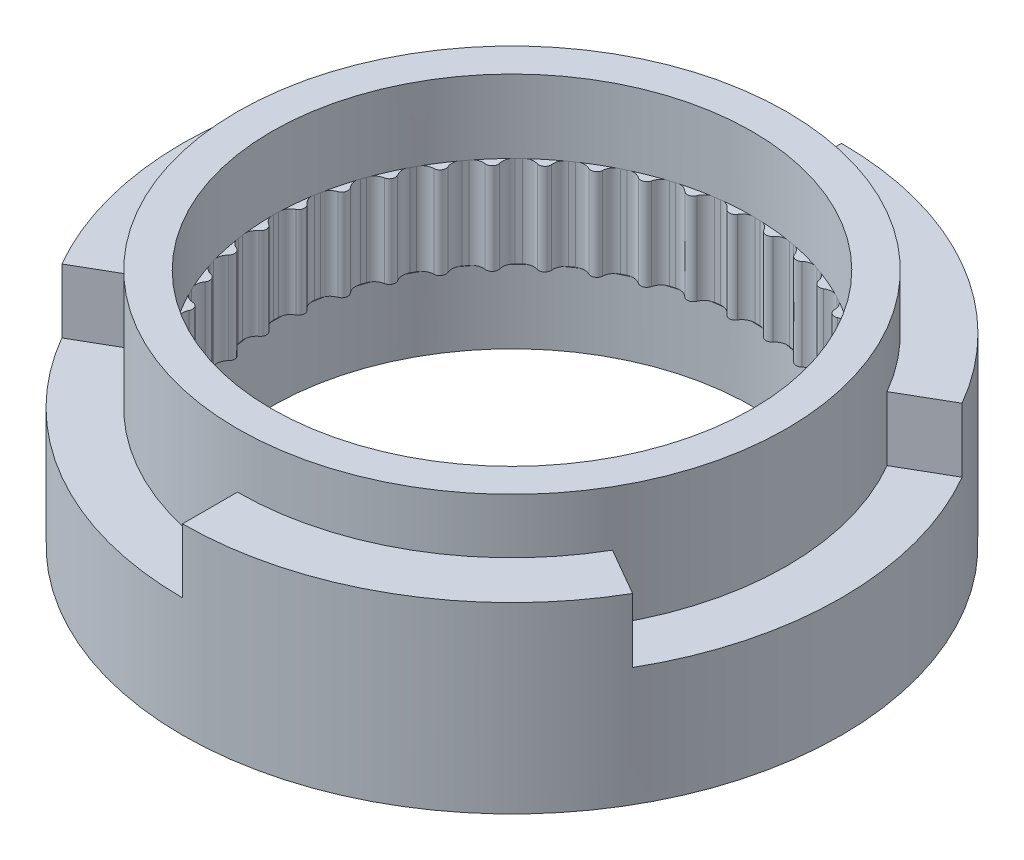
from build123d import *

# Parameters (mm, degrees)
SKETCH1_R                = 30
BOSS_EXTRUDE1_DEPTH      = 5
BOSS_EXTRUDE1_DEPTH_BACK = 5
SKETCH3_R                = 30
SKETCH3_R_2              = 26.25
BOSS_EXTRUDE2_DEPTH      = 8
SKETCH4_R                = 36
SKETCH4_R_2              = 30
BOSS_EXTRUDE3_DEPTH      = 13
BOSS_EXTRUDE4_DEPTH      = 7


with BuildPart() as part:
    # Sketch1 → Boss-Extrude1 (new, two sides)
    with BuildSketch(Plane(origin=(0, 0, 0), x_dir=(0.9998001362045251, 0, 0.01999218961027602), z_dir=(0, 1, 0))) as boss_extrude1_sk:
        with Locations(Location((0, 0, 0), (0, 0, 181.145544407))):
            Circle(SKETCH1_R)
        with BuildLine():
            ThreePointArc((-25.509521388, -2.579136659), (-25.936481137, -3.146205235), (-26.019455243, -3.851170975))
            ThreePointArc((-26.019455243, -3.851170975), (-25.978262474, -4.119884448), (-25.934294667, -4.388157829))
            ThreePointArc((-25.934294667, -4.388157829), (-25.634532236, -5.041831047), (-25.047634104, -5.457399062))
            ThreePointArc((-25.047634104, -5.457399062), (-24.629999462, -5.929109709), (-24.791990986, -6.537951539))
            ThreePointArc((-24.791990986, -6.537951539), (-25.124985082, -7.16482978), (-25.096656701, -7.874096231))
            ThreePointArc((-25.096656701, -7.874096231), (-25.013935035, -8.133057427), (-24.928541342, -8.391149836))
            ThreePointArc((-24.928541342, -8.391149836), (-24.530212463, -8.989882077), (-23.885530861, -9.308522665))
            ThreePointArc((-23.885530861, -9.308522665), (-23.399246192, -9.709093319), (-23.463999485, -10.335780353))
            ThreePointArc((-23.463999485, -10.335780353), (-23.694828509, -11.007032436), (-23.55589518, -11.703135106))
            ThreePointArc((-23.55589518, -11.703135106), (-23.433681498, -11.945967539), (-23.308964596, -12.187523887))
            ThreePointArc((-23.308964596, -12.187523887), (-22.821877448, -12.716572375), (-22.135286577, -12.930439547))
            ThreePointArc((-22.135286577, -12.930439547), (-21.592325823, -13.250006829), (-21.558246445, -13.879107953))
            ThreePointArc((-21.558246445, -13.879107953), (-21.68122662, -14.578205424), (-21.435109342, -15.244003953))
            ThreePointArc((-21.435109342, -15.244003953), (-21.276412952, -15.464728285), (-21.115443783, -15.683800651))
            ThreePointArc((-21.115443783, -15.683800651), (-20.55159207, -16.130138457), (-19.839998074, -16.233966094))
            ThreePointArc((-19.839998074, -16.233966094), (-19.253730731, -16.464661197), (-19.12165783, -17.080685853))
            ThreePointArc((-19.12165783, -17.080685853), (-19.133760976, -17.790414611), (-18.786519973, -18.409514831))
            ThreePointArc((-18.786519973, -18.409514831), (-18.595248506, -18.602696095), (-18.401990667, -18.793890191))
            ThreePointArc((-18.401990667, -18.793890191), (-17.775258287, -19.146526997), (-17.056182974, -19.137758518))
            ThreePointArc((-17.056182974, -19.137758518), (-16.44104489, -19.273900963), (-16.214230537, -19.86168058))
            ThreePointArc((-16.214230537, -19.86168058), (-16.115158635, -20.564564749), (-15.675344133, -21.121722357))
            ThreePointArc((-15.675344133, -21.121722357), (-15.456207328, -21.282603789), (-15.235419467, -21.441211782))
            ThreePointArc((-15.235419467, -21.441211782), (-14.561238653, -21.691464499), (-13.852388043, -21.570315812))
            ThreePointArc((-13.852388043, -21.570315812), (-13.223525958, -21.608553321), (-12.907555077, -22.153614813))
            ThreePointArc((-12.907555077, -22.153614813), (-12.699747605, -22.832347052), (-12.178189298, -23.313842979))
            ThreePointArc((-12.178189298, -23.313842979), (-11.936583029, -23.438463145), (-11.693701677, -23.560579579))
            ThreePointArc((-11.693701677, -23.560579579), (-10.988672997, -23.702286156), (-10.307501344, -23.471740344))
            ThreePointArc((-10.307501344, -23.471740344), (-9.680399932, -23.411131382), (-9.283052773, -23.900053527))
            ThreePointArc((-9.283052773, -23.900053527), (-8.971626642, -24.537921194), (-8.381167024, -24.931899413))
            ThreePointArc((-8.381167024, -24.931899413), (-8.123040441, -25.017189751), (-7.864046142, -25.099807714))
            ThreePointArc((-7.864046142, -25.099807714), (-7.145529743, -25.129478863), (-6.508809754, -24.79521273))
            ThreePointArc((-6.508809754, -24.79521273), (-5.898910331, -24.637249691), (-5.429970901, -25.057993602))
            ThreePointArc((-5.429970901, -25.057993602), (-5.022594455, -25.63929028), (-4.377772603, -25.936049739))
            ThreePointArc((-4.377772603, -25.936049739), (-4.109481638, -25.979910117), (-3.840751692, -26.020995282))
            ThreePointArc((-3.840751692, -26.020995282), (-3.126439832, -25.937900401), (-2.549849667, -25.508144687))
            ThreePointArc((-2.549849667, -25.508144687), (-1.972169981, -25.256717146), (-1.443185125, -25.598922713))
            ThreePointArc((-1.443185125, -25.598922713), (-0.949889324, -26.109334947), (-0.266582892, -26.301568443))
            ThreePointArc((-0.266582892, -26.301568443), (0.005266241, -26.302918874), (0.277114812, -26.301459587))
            ThreePointArc((0.277114812, -26.301459587), (0.969633404, -26.107644748), (1.471896182, -25.592981467))
            ThreePointArc((1.471896182, -25.592981467), (2.00313174, -25.254280402), (2.579136659, -25.509521388))
            ThreePointArc((2.579136659, -25.509521388), (3.146205235, -25.936481137), (3.851170975, -26.019455243))
            ThreePointArc((3.851170975, -26.019455243), (4.119884448, -25.978262474), (4.388157829, -25.934294667))
            ThreePointArc((4.388157829, -25.934294667), (5.041831047, -25.634532236), (5.457399062, -25.047634104))
            ThreePointArc((5.457399062, -25.047634104), (5.929109709, -24.629999462), (6.537951539, -24.791990986))
            ThreePointArc((6.537951539, -24.791990986), (7.16482978, -25.124985082), (7.874096231, -25.096656701))
            ThreePointArc((7.874096231, -25.096656701), (8.133057427, -25.013935035), (8.391149836, -24.928541342))
            ThreePointArc((8.391149836, -24.928541342), (8.989882077, -24.530212463), (9.308522665, -23.885530861))
            ThreePointArc((9.308522665, -23.885530861), (9.709093319, -23.399246192), (10.335780353, -23.463999485))
            ThreePointArc((10.335780353, -23.463999485), (11.007032436, -23.694828509), (11.703135106, -23.55589518))
            ThreePointArc((11.703135106, -23.55589518), (11.945967539, -23.433681498), (12.187523887, -23.308964596))
            ThreePointArc((12.187523887, -23.308964596), (12.716572375, -22.821877448), (12.930439547, -22.135286577))
            ThreePointArc((12.930439547, -22.135286577), (13.250006829, -21.592325823), (13.879107953, -21.558246445))
            ThreePointArc((13.879107953, -21.558246445), (14.578205424, -21.68122662), (15.244003953, -21.435109342))
            ThreePointArc((15.244003953, -21.435109342), (15.464728285, -21.276412952), (15.683800651, -21.115443783))
            ThreePointArc((15.683800651, -21.115443783), (16.130138457, -20.55159207), (16.233966094, -19.839998074))
            ThreePointArc((16.233966094, -19.839998074), (16.464661197, -19.253730731), (17.080685853, -19.12165783))
            ThreePointArc((17.080685853, -19.12165783), (17.790414611, -19.133760976), (18.409514831, -18.786519973))
            ThreePointArc((18.409514831, -18.786519973), (18.602696095, -18.595248506), (18.793890191, -18.401990667))
            ThreePointArc((18.793890191, -18.401990667), (19.146526997, -17.775258287), (19.137758518, -17.056182974))
            ThreePointArc((19.137758518, -17.056182974), (19.273900963, -16.44104489), (19.86168058, -16.214230537))
            ThreePointArc((19.86168058, -16.214230537), (20.564564749, -16.115158635), (21.121722357, -15.675344133))
            ThreePointArc((21.121722357, -15.675344133), (21.282603789, -15.456207328), (21.441211782, -15.235419467))
            ThreePointArc((21.441211782, -15.235419467), (21.691464499, -14.561238653), (21.570315812, -13.852388043))
            ThreePointArc((21.570315812, -13.852388043), (21.608553321, -13.223525958), (22.153614813, -12.907555077))
            ThreePointArc((22.153614813, -12.907555077), (22.832347052, -12.699747605), (23.313842979, -12.178189298))
            ThreePointArc((23.313842979, -12.178189298), (23.438463145, -11.936583029), (23.560579579, -11.693701677))
            ThreePointArc((23.560579579, -11.693701677), (23.702286156, -10.988672997), (23.471740344, -10.307501344))
            ThreePointArc((23.471740344, -10.307501344), (23.411131382, -9.680399932), (23.900053527, -9.283052773))
            ThreePointArc((23.900053527, -9.283052773), (24.537921194, -8.971626642), (24.931899413, -8.381167024))
            ThreePointArc((24.931899413, -8.381167024), (25.017189751, -8.123040441), (25.099807714, -7.864046142))
            ThreePointArc((25.099807714, -7.864046142), (25.129478863, -7.145529743), (24.79521273, -6.508809754))
            ThreePointArc((24.79521273, -6.508809754), (24.637249691, -5.898910331), (25.057993602, -5.429970901))
            ThreePointArc((25.057993602, -5.429970901), (25.63929028, -5.022594455), (25.936049739, -4.377772603))
            ThreePointArc((25.936049739, -4.377772603), (25.979910117, -4.109481638), (26.020995282, -3.840751692))
            ThreePointArc((26.020995282, -3.840751692), (25.937900401, -3.126439832), (25.508144687, -2.549849667))
            ThreePointArc((25.508144687, -2.549849667), (25.256717146, -1.972169981), (25.598922713, -1.443185125))
            ThreePointArc((25.598922713, -1.443185125), (26.109334947, -0.949889324), (26.301568443, -0.266582892))
            ThreePointArc((26.301568443, -0.266582892), (26.302918874, 0.005266241), (26.301459587, 0.277114812))
            ThreePointArc((26.301459587, 0.277114812), (26.107644748, 0.969633404), (25.592981467, 1.471896182))
            ThreePointArc((25.592981467, 1.471896182), (25.254280402, 2.00313174), (25.509521388, 2.579136659))
            ThreePointArc((25.509521388, 2.579136659), (25.936481137, 3.146205235), (26.019455243, 3.851170975))
            ThreePointArc((26.019455243, 3.851170975), (25.978262474, 4.119884448), (25.934294667, 4.388157829))
            ThreePointArc((25.934294667, 4.388157829), (25.634532236, 5.041831047), (25.047634104, 5.457399062))
            ThreePointArc((25.047634104, 5.457399062), (24.629999462, 5.929109709), (24.791990986, 6.537951539))
            ThreePointArc((24.791990986, 6.537951539), (25.124985082, 7.16482978), (25.096656701, 7.874096231))
            ThreePointArc((25.096656701, 7.874096231), (25.013935035, 8.133057427), (24.928541342, 8.391149836))
            ThreePointArc((24.928541342, 8.391149836), (24.530212463, 8.989882077), (23.885530861, 9.308522665))
            ThreePointArc((23.885530861, 9.308522665), (23.399246192, 9.709093319), (23.463999485, 10.335780353))
            ThreePointArc((23.463999485, 10.335780353), (23.694828509, 11.007032436), (23.55589518, 11.703135106))
            ThreePointArc((23.55589518, 11.703135106), (23.433681498, 11.945967539), (23.308964596, 12.187523887))
            ThreePointArc((23.308964596, 12.187523887), (22.821877448, 12.716572375), (22.135286577, 12.930439547))
            ThreePointArc((22.135286577, 12.930439547), (21.592325823, 13.250006829), (21.558246445, 13.879107953))
            ThreePointArc((21.558246445, 13.879107953), (21.68122662, 14.578205424), (21.435109342, 15.244003953))
            ThreePointArc((21.435109342, 15.244003953), (21.276412952, 15.464728285), (21.115443783, 15.683800651))
            ThreePointArc((21.115443783, 15.683800651), (20.55159207, 16.130138457), (19.839998074, 16.233966094))
            ThreePointArc((19.839998074, 16.233966094), (19.253730731, 16.464661197), (19.12165783, 17.080685853))
            ThreePointArc((19.12165783, 17.080685853), (19.133760976, 17.790414611), (18.786519973, 18.409514831))
            ThreePointArc((18.786519973, 18.409514831), (18.595248506, 18.602696095), (18.401990667, 18.793890191))
            ThreePointArc((18.401990667, 18.793890191), (17.775258287, 19.146526997), (17.056182974, 19.137758518))
            ThreePointArc((17.056182974, 19.137758518), (16.44104489, 19.273900963), (16.214230537, 19.86168058))
            ThreePointArc((16.214230537, 19.86168058), (16.115158635, 20.564564749), (15.675344133, 21.121722357))
            ThreePointArc((15.675344133, 21.121722357), (15.456207328, 21.282603789), (15.235419467, 21.441211782))
            ThreePointArc((15.235419467, 21.441211782), (14.561238653, 21.691464499), (13.852388043, 21.570315812))
            ThreePointArc((13.852388043, 21.570315812), (13.223525958, 21.608553321), (12.907555077, 22.153614813))
            ThreePointArc((12.907555077, 22.153614813), (12.699747605, 22.832347052), (12.178189298, 23.313842979))
            ThreePointArc((12.178189298, 23.313842979), (11.936583029, 23.438463145), (11.693701677, 23.560579579))
            ThreePointArc((11.693701677, 23.560579579), (10.988672997, 23.702286156), (10.307501344, 23.471740344))
            ThreePointArc((10.307501344, 23.471740344), (9.680399932, 23.411131382), (9.283052773, 23.900053527))
            ThreePointArc((9.283052773, 23.900053527), (8.971626642, 24.537921194), (8.381167024, 24.931899413))
            ThreePointArc((8.381167024, 24.931899413), (8.123040441, 25.017189751), (7.864046142, 25.099807714))
            ThreePointArc((7.864046142, 25.099807714), (7.145529743, 25.129478863), (6.508809754, 24.79521273))
            ThreePointArc((6.508809754, 24.79521273), (5.898910331, 24.637249691), (5.429970901, 25.057993602))
            ThreePointArc((5.429970901, 25.057993602), (5.022594455, 25.63929028), (4.377772603, 25.936049739))
            ThreePointArc((4.377772603, 25.936049739), (4.109481638, 25.979910117), (3.840751692, 26.020995282))
            ThreePointArc((3.840751692, 26.020995282), (3.126439832, 25.937900401), (2.549849667, 25.508144687))
            ThreePointArc((2.549849667, 25.508144687), (1.972169981, 25.256717146), (1.443185125, 25.598922713))
            ThreePointArc((1.443185125, 25.598922713), (0.949889324, 26.109334947), (0.266582892, 26.301568443))
            ThreePointArc((0.266582892, 26.301568443), (-0.005266241, 26.302918874), (-0.277114812, 26.301459587))
            ThreePointArc((-0.277114812, 26.301459587), (-0.969633404, 26.107644748), (-1.471896182, 25.592981467))
            ThreePointArc((-1.471896182, 25.592981467), (-2.00313174, 25.254280402), (-2.579136659, 25.509521388))
            ThreePointArc((-2.579136659, 25.509521388), (-3.146205235, 25.936481137), (-3.851170975, 26.019455243))
            ThreePointArc((-3.851170975, 26.019455243), (-4.119884448, 25.978262474), (-4.388157829, 25.934294667))
            ThreePointArc((-4.388157829, 25.934294667), (-5.041831047, 25.634532236), (-5.457399062, 25.047634104))
            ThreePointArc((-5.457399062, 25.047634104), (-5.929109709, 24.629999462), (-6.537951539, 24.791990986))
            ThreePointArc((-6.537951539, 24.791990986), (-7.16482978, 25.124985082), (-7.874096231, 25.096656701))
            ThreePointArc((-7.874096231, 25.096656701), (-8.133057427, 25.013935035), (-8.391149836, 24.928541342))
            ThreePointArc((-8.391149836, 24.928541342), (-8.989882077, 24.530212463), (-9.308522665, 23.885530861))
            ThreePointArc((-9.308522665, 23.885530861), (-9.709093319, 23.399246192), (-10.335780353, 23.463999485))
            ThreePointArc((-10.335780353, 23.463999485), (-11.007032436, 23.694828509), (-11.703135106, 23.55589518))
            ThreePointArc((-11.703135106, 23.55589518), (-11.945967539, 23.433681498), (-12.187523887, 23.308964596))
            ThreePointArc((-12.187523887, 23.308964596), (-12.716572375, 22.821877448), (-12.930439547, 22.135286577))
            ThreePointArc((-12.930439547, 22.135286577), (-13.250006829, 21.592325823), (-13.879107953, 21.558246445))
            ThreePointArc((-13.879107953, 21.558246445), (-14.578205424, 21.68122662), (-15.244003953, 21.435109342))
            ThreePointArc((-15.244003953, 21.435109342), (-15.464728285, 21.276412952), (-15.683800651, 21.115443783))
            ThreePointArc((-15.683800651, 21.115443783), (-16.130138457, 20.55159207), (-16.233966094, 19.839998074))
            ThreePointArc((-16.233966094, 19.839998074), (-16.464661197, 19.253730731), (-17.080685853, 19.12165783))
            ThreePointArc((-17.080685853, 19.12165783), (-17.790414611, 19.133760976), (-18.409514831, 18.786519973))
            ThreePointArc((-18.409514831, 18.786519973), (-18.602696095, 18.595248506), (-18.793890191, 18.401990667))
            ThreePointArc((-18.793890191, 18.401990667), (-19.146526997, 17.775258287), (-19.137758518, 17.056182974))
            ThreePointArc((-19.137758518, 17.056182974), (-19.273900963, 16.44104489), (-19.86168058, 16.214230537))
            ThreePointArc((-19.86168058, 16.214230537), (-20.564564749, 16.115158635), (-21.121722357, 15.675344133))
            ThreePointArc((-21.121722357, 15.675344133), (-21.282603789, 15.456207328), (-21.441211782, 15.235419467))
            ThreePointArc((-21.441211782, 15.235419467), (-21.691464499, 14.561238653), (-21.570315812, 13.852388043))
            ThreePointArc((-21.570315812, 13.852388043), (-21.608553321, 13.223525958), (-22.153614813, 12.907555077))
            ThreePointArc((-22.153614813, 12.907555077), (-22.832347052, 12.699747605), (-23.313842979, 12.178189298))
            ThreePointArc((-23.313842979, 12.178189298), (-23.438463145, 11.936583029), (-23.560579579, 11.693701677))
            ThreePointArc((-23.560579579, 11.693701677), (-23.702286156, 10.988672997), (-23.471740344, 10.307501344))
            ThreePointArc((-23.471740344, 10.307501344), (-23.411131382, 9.680399932), (-23.900053527, 9.283052773))
            ThreePointArc((-23.900053527, 9.283052773), (-24.537921194, 8.971626642), (-24.931899413, 8.381167024))
            ThreePointArc((-24.931899413, 8.381167024), (-25.017189751, 8.123040441), (-25.099807714, 7.864046142))
            ThreePointArc((-25.099807714, 7.864046142), (-25.129478863, 7.145529743), (-24.79521273, 6.508809754))
            ThreePointArc((-24.79521273, 6.508809754), (-24.637249691, 5.898910331), (-25.057993602, 5.429970901))
            ThreePointArc((-25.057993602, 5.429970901), (-25.63929028, 5.022594455), (-25.936049739, 4.377772603))
            ThreePointArc((-25.936049739, 4.377772603), (-25.979910117, 4.109481638), (-26.020995282, 3.840751692))
            ThreePointArc((-26.020995282, 3.840751692), (-25.937900401, 3.126439832), (-25.508144687, 2.549849667))
            ThreePointArc((-25.508144687, 2.549849667), (-25.256717146, 1.972169981), (-25.598922713, 1.443185125))
            ThreePointArc((-25.598922713, 1.443185125), (-26.109334947, 0.949889324), (-26.301568443, 0.266582892))
            ThreePointArc((-26.301568443, 0.266582892), (-26.302918874, -0.005266241), (-26.301459587, -0.277114812))
            ThreePointArc((-26.301459587, -0.277114812), (-26.107644748, -0.969633404), (-25.592981467, -1.471896182))
            ThreePointArc((-25.592981467, -1.471896182), (-25.254280402, -2.00313174), (-25.509521388, -2.579136659))
        make_face(mode=Mode.SUBTRACT)
    extrude(amount=BOSS_EXTRUDE1_DEPTH)
    extrude(boss_extrude1_sk.sketch, amount=-BOSS_EXTRUDE1_DEPTH_BACK)

    # Sketch3 → Boss-Extrude2 (add)
    with BuildSketch(Plane(origin=(0, 5, 0), x_dir=(1, 0, 0), z_dir=(0, 1, 0))):
        with Locations(Location((0, 0, 0), (0, 0, 180))):
            Circle(SKETCH3_R)
        with Locations(Location((0, 0, 0), (0, 0, 90.308068643))):
            Circle(SKETCH3_R_2, mode=Mode.SUBTRACT)
    boss_extrude2 = extrude(amount=BOSS_EXTRUDE2_DEPTH)

    # Mirror1: Boss-Extrude2 across plane
    add(boss_extrude2.mirror(Plane.ZX))

    # Sketch4 → Boss-Extrude3 (add)
    with BuildSketch(Plane(origin=(0, 0, 0), x_dir=(1, 0, 0), z_dir=(0, 1, 0))):
        with Locations(Location((0, 0, 0), (0, 0, 270))):
            Circle(SKETCH4_R)
        with Locations(Location((0, 0, 0), (0, 0, 270))):
            Circle(SKETCH4_R_2, mode=Mode.SUBTRACT)
    extrude(amount=-BOSS_EXTRUDE3_DEPTH)

    # Sketch6 → Boss-Extrude4 (add)
    with BuildSketch(Plane(origin=(0, 0, 0), x_dir=(1, 0, 0), z_dir=(0, 1, 0))):
        with BuildLine():
            Line((-31.176914536, -18), (-25.980762114, -15))
            ThreePointArc((-25.980762114, -15), (-30, 0), (-25.980762114, 15))
            Line((-25.980762114, 15), (-31.176914536, 18))
            ThreePointArc((-31.176914536, 18), (-36, 0), (-31.176914536, -18))
        make_face()
        with BuildLine():
            Line((31.176914536, -18), (25.980762114, -15))
            ThreePointArc((25.980762114, -15), (15, -25.980762114), (0, -30))
            Line((0, -30), (0, -36))
            ThreePointArc((0, -36), (18, -31.176914536), (31.176914536, -18))
        make_face()
        with BuildLine():
            Line((0, 36), (0, 30))
            ThreePointArc((0, 30), (15, 25.980762114), (25.980762114, 15))
            Line((25.980762114, 15), (31.176914536, 18))
            ThreePointArc((31.176914536, 18), (18, 31.176914536), (0, 36))
        make_face()
    extrude(amount=BOSS_EXTRUDE4_DEPTH)


solid = part.part
